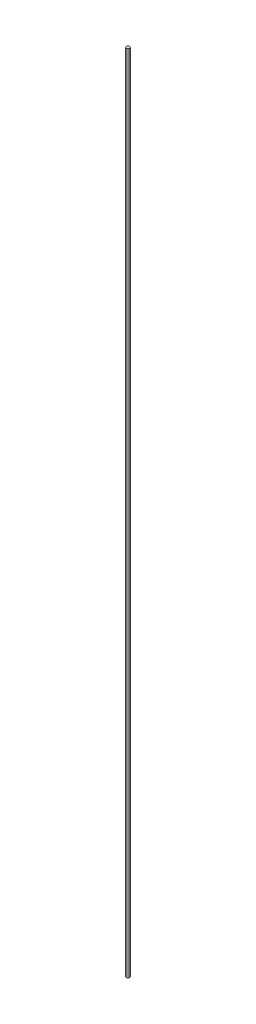
from build123d import *

# Parameters (mm, degrees)
SKETCH1_R           = 0.3225
BOSS_EXTRUDE1_DEPTH = 155


with BuildPart() as part:
    # Sketch1 → Boss-Extrude1 (new body)
    with BuildSketch(Plane(origin=(0, 0, 0), x_dir=(1, 0, 0), z_dir=(0, 1, 0))):
        Circle(SKETCH1_R)
    extrude(amount=BOSS_EXTRUDE1_DEPTH)


solid = part.part
